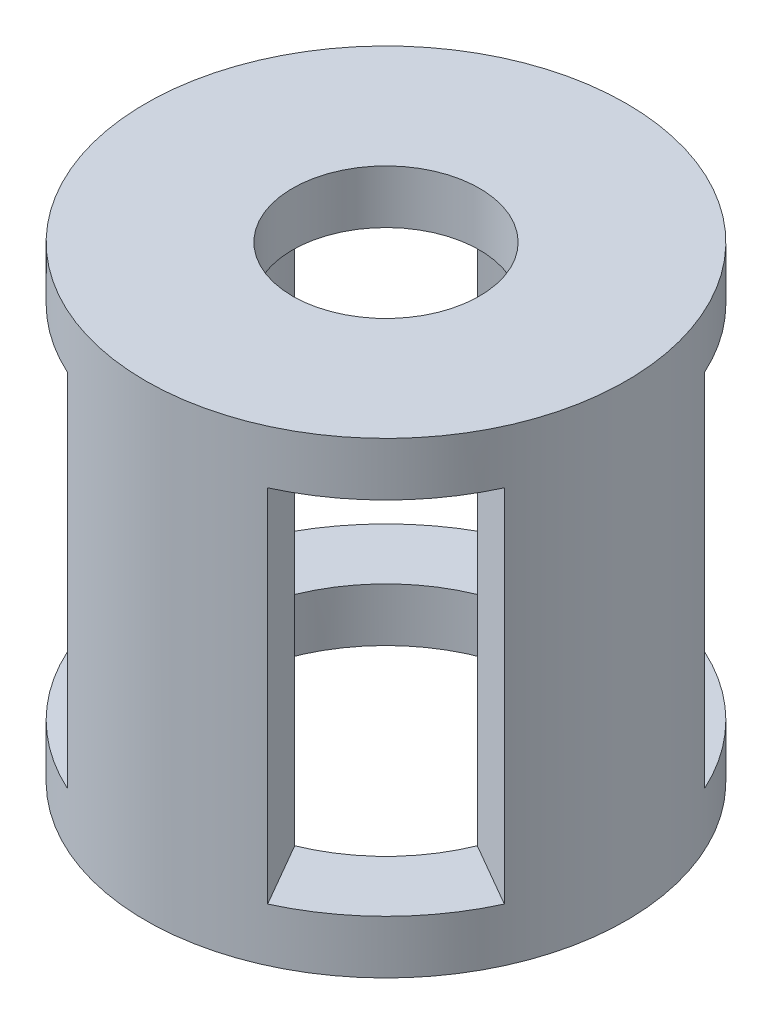
from build123d import *
from build123d.topology import SkipClean

# Parameters (mm, degrees)
SKETCH1_R                = 18
SKETCH1_R_2              = 7
BOSS_EXTRUDE1_DEPTH      = 4
BOSS_EXTRUDE2_START      = 30
BOSS_EXTRUDE2_DEPTH      = 30
BOSS_EXTRUDE3_DEPTH      = 1
BOSS_EXTRUDE3_DEPTH_BACK = 3
SKETCH3_R                = 18
SKETCH3_R_2              = 12.5


with BuildPart() as part:
    # Sketch1 → Boss-Extrude1 (new body)
    with BuildSketch(Plane(origin=(0, 0, 0), x_dir=(1, 0, 0), z_dir=(0, 1, 0))):
        Circle(SKETCH1_R)
        Circle(SKETCH1_R_2, mode=Mode.SUBTRACT)
    extrude(amount=BOSS_EXTRUDE1_DEPTH)

    # Sketch2 → Boss-Extrude2 (add)
    with SkipClean():  # the faces are left unmerged after this step: merging them gives an invalid solid
        with BuildSketch(Plane.XZ.offset(BOSS_EXTRUDE2_START)):
            with BuildLine():
                Line((4.732447384, 11.569526428), (7.5, 16.363068172))
                ThreePointArc((7.5, 16.363068172), (0, 18), (-7.5, 16.363068172))
                Line((-7.5, 16.363068172), (-4.732447384, 11.569526428))
                ThreePointArc((-4.732447384, 11.569526428), (0, 12.5), (4.732447384, 11.569526428))
            make_face()
            with BuildLine():
                Line((11.569526428, -4.732447384), (16.363068172, -7.5))
                ThreePointArc((16.363068172, -7.5), (18, 0), (16.363068172, 7.5))
                Line((16.363068172, 7.5), (11.569526428, 4.732447384))
                ThreePointArc((11.569526428, 4.732447384), (12.5, 0), (11.569526428, -4.732447384))
            make_face()
            with BuildLine():
                Line((-4.732447384, -11.569526428), (-7.5, -16.363068172))
                ThreePointArc((-7.5, -16.363068172), (0, -18), (7.5, -16.363068172))
                Line((7.5, -16.363068172), (4.732447384, -11.569526428))
                ThreePointArc((4.732447384, -11.569526428), (0, -12.5), (-4.732447384, -11.569526428))
            make_face()
            with BuildLine():
                Line((-11.569526428, 4.732447384), (-16.363068172, 7.5))
                ThreePointArc((-16.363068172, 7.5), (-18, 0), (-16.363068172, -7.5))
                Line((-16.363068172, -7.5), (-11.569526428, -4.732447384))
                ThreePointArc((-11.569526428, -4.732447384), (-12.5, 0), (-11.569526428, 4.732447384))
            make_face()
        extrude(amount=-BOSS_EXTRUDE2_DEPTH)

    # Sketch3 → Boss-Extrude3 (add, two sides: drawn at the far end of the back side and taken through both)
    with SkipClean():  # the faces are left unmerged after this step: merging them gives an invalid solid
        with BuildSketch(Plane.XZ.offset(30).offset(-BOSS_EXTRUDE3_DEPTH_BACK)):
            Circle(SKETCH3_R)
            Circle(SKETCH3_R_2, mode=Mode.SUBTRACT)
        extrude(amount=BOSS_EXTRUDE3_DEPTH + BOSS_EXTRUDE3_DEPTH_BACK)


solid = part.part
